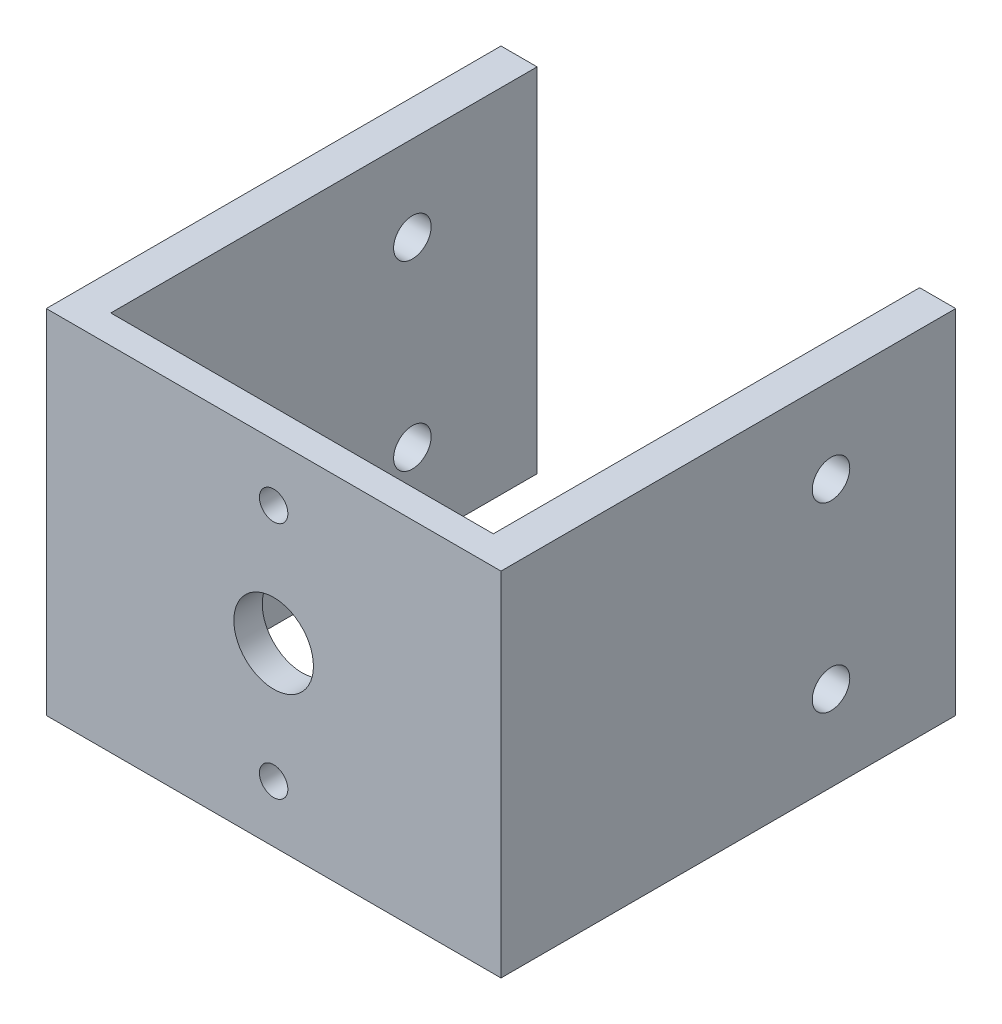
from build123d import *

# Parameters (mm, degrees)
SKETCH3_W           = 33.65
SKETCH3_H           = 31
SKETCH3_R           = 1.25
SKETCH3_R_2         = 3.5
BOSS_EXTRUDE3_DEPTH = 2.5
SKETCH3_3_W         = 3.175
SKETCH3_3_H         = 31
BOSS_EXTRUDE4_DEPTH = 40
SKETCH4_R           = 1.65
CUT_EXTRUDE1_DEPTH  = 40


with BuildPart() as part:
    # Sketch3 → Boss-Extrude3 (new body)
    with BuildSketch(Plane.XY):
        with Locations((0, 15.5)):
            Rectangle(SKETCH3_W, SKETCH3_H)
        with Locations((0, 5)):
            Circle(SKETCH3_R, mode=Mode.SUBTRACT)
        with Locations((0, 15.5)):
            Circle(SKETCH3_R_2, mode=Mode.SUBTRACT)
        with Locations((0, 26)):
            Circle(SKETCH3_R, mode=Mode.SUBTRACT)
    extrude(amount=-BOSS_EXTRUDE3_DEPTH)

    # Sketch3_3 → Boss-Extrude4 (add)
    with BuildSketch(Plane.XY):
        with Locations((-18.4125, 15.5)):
            Rectangle(SKETCH3_3_W, SKETCH3_3_H)
        with Locations((18.4125, 15.5)):
            Rectangle(SKETCH3_3_W, SKETCH3_3_H)
    extrude(amount=-BOSS_EXTRUDE4_DEPTH)

    # Sketch4 → Cut-Extrude1 (cut)
    with BuildSketch(Plane.ZY.offset(20)):
        with Locations((-29.03, 23.5)):
            Circle(SKETCH4_R)
        with Locations((-29.03, 7.5)):
            Circle(SKETCH4_R)
    extrude(amount=-CUT_EXTRUDE1_DEPTH, mode=Mode.SUBTRACT)


solid = part.part
